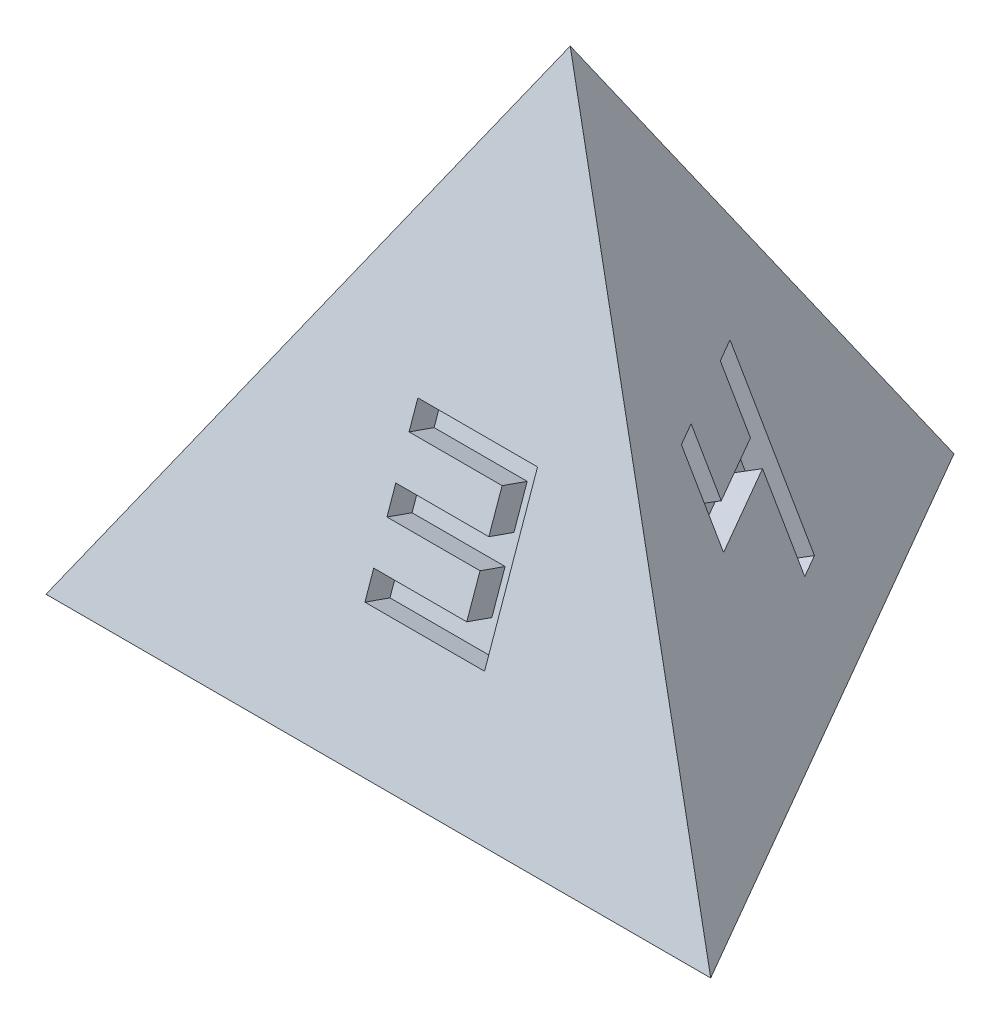
from build123d import *

# Parameters (mm, degrees)
CUT_EXTRUDE1_DEPTH      = 0.508
CUT_EXTRUDE2_DEPTH      = 0.508
CUT_EXTRUDE3_DEPTH      = 0.508
CUT_EXTRUDE4_DEPTH      = 15.231557685
CUT_EXTRUDE4_DEPTH_BACK = 0.508
SKETCH8_W               = 2.54
SKETCH8_H               = 0.508
SKETCH8_W_2             = 1.524
SKETCH8_H_2             = 1.016


with BuildPart() as part:
    # Sketch1 → Loft1 section 0
    with BuildSketch(Plane(origin=(0, 0, 0), x_dir=(1, 0, 0), z_dir=(0, 1, 0)), mode=Mode.PRIVATE) as loft1_s0:
        with BuildLine():
            Line((0, 7.332348419), (-6.35, -3.666174209))
            Line((-6.35, -3.666174209), (6.35, -3.666174209))
            Line((6.35, -3.666174209), (0, 7.332348419))
        make_face()
    loft([Vertex(0, 10.414, 0), loft1_s0.sketch])

    # Sketch4 → Cut-Extrude1 (cut)
    with BuildSketch(Plane(origin=(0, 1.148332745, 3.26191188), x_dir=(1, 0, 0), z_dir=(6.377659034928701e-15, 0.3320665177261577, 0.9432559715184545))):
        Polygon((-1.016, 2.846586297), (-1.016, 2.338586297), (0.762, 2.338586297), (0.762, 1.576586297), (-1.016, 1.576586297), (-1.016, 1.068586297), (1.27, 1.068586297), (1.27, 4.116586297), (-1.016, 4.116586297), (-1.016, 3.608586297), (0.762, 3.608586297), (0.762, 2.846586297), align=None)
    extrude(amount=-CUT_EXTRUDE1_DEPTH, mode=Mode.SUBTRACT)

    # Sketch6 → Cut-Extrude2 (cut)
    with BuildSketch(Plane(origin=(2.824898553, 1.148332745, -1.63095594), x_dir=(-0.4369088483314536, -0.17760522289896655, -0.881797620233062), z_dir=(0.8168836336063492, 0.33206651772616136, -0.47162798575923026))):
        Polygon((0.212388142, 2.939147635), (-1.28435293, 2.652194393), (-1.523480632, 3.899478619), (-2.022394323, 3.803827539), (-1.68761554, 2.057629621), (0.308039223, 2.440233945), (0.642818006, 0.694036027), (1.141731697, 0.789687108), (0.47217413, 4.282082943), (-0.02673956, 4.186431862), align=None)
    extrude(amount=-CUT_EXTRUDE2_DEPTH, mode=Mode.SUBTRACT)

    # Sketch7 → Cut-Extrude3 (cut)
    with BuildSketch(Plane(origin=(-2.824898553, 1.148332745, -1.63095594), x_dir=(-0.43690884833145016, 0.17760522289896236, 0.8817976202330645), z_dir=(-0.8168836336063534, 0.3320665177261578, -0.47162798575922543))):
        Polygon((1.725111937, 3.602196234), (-0.519999671, 4.032626098), (-0.854778454, 2.28642818), (1.140876309, 1.903823857), (0.997399687, 1.155453321), (-0.74879823, 1.490232104), (-0.844449311, 0.991318413), (1.400662297, 0.560888549), (1.73544108, 2.307086467), (-0.260213682, 2.68969079), (-0.116737061, 3.438061326), (1.629460856, 3.103282543), align=None)
    extrude(amount=-CUT_EXTRUDE3_DEPTH, mode=Mode.SUBTRACT)

    # Sketch8 → Cut-Extrude4 (cut, two sides: drawn at the far end of the back side and taken through both)
    # profile 1 of 2: a face of its own
    with BuildSketch(Plane.XZ.offset(-CUT_EXTRUDE4_DEPTH_BACK)):
        with Locations((0, 2.794)):
            Rectangle(SKETCH8_W, SKETCH8_H)
    # profile 2 of 2: a face of its own
    with BuildSketch(Plane.XZ.offset(-CUT_EXTRUDE4_DEPTH_BACK)):
        Polygon((1.27, 1.778), (-1.27, 1.778), (-1.27, -0.254), (0.762, -0.254), (0.762, -1.27), (-1.016, -1.27), (-1.016, -1.778), (1.27, -1.778), align=None)
        with Locations((0, 0.762)):
            Rectangle(SKETCH8_W_2, SKETCH8_H_2, mode=Mode.SUBTRACT)
    extrude(amount=CUT_EXTRUDE4_DEPTH + CUT_EXTRUDE4_DEPTH_BACK, mode=Mode.SUBTRACT)


solid = part.part
